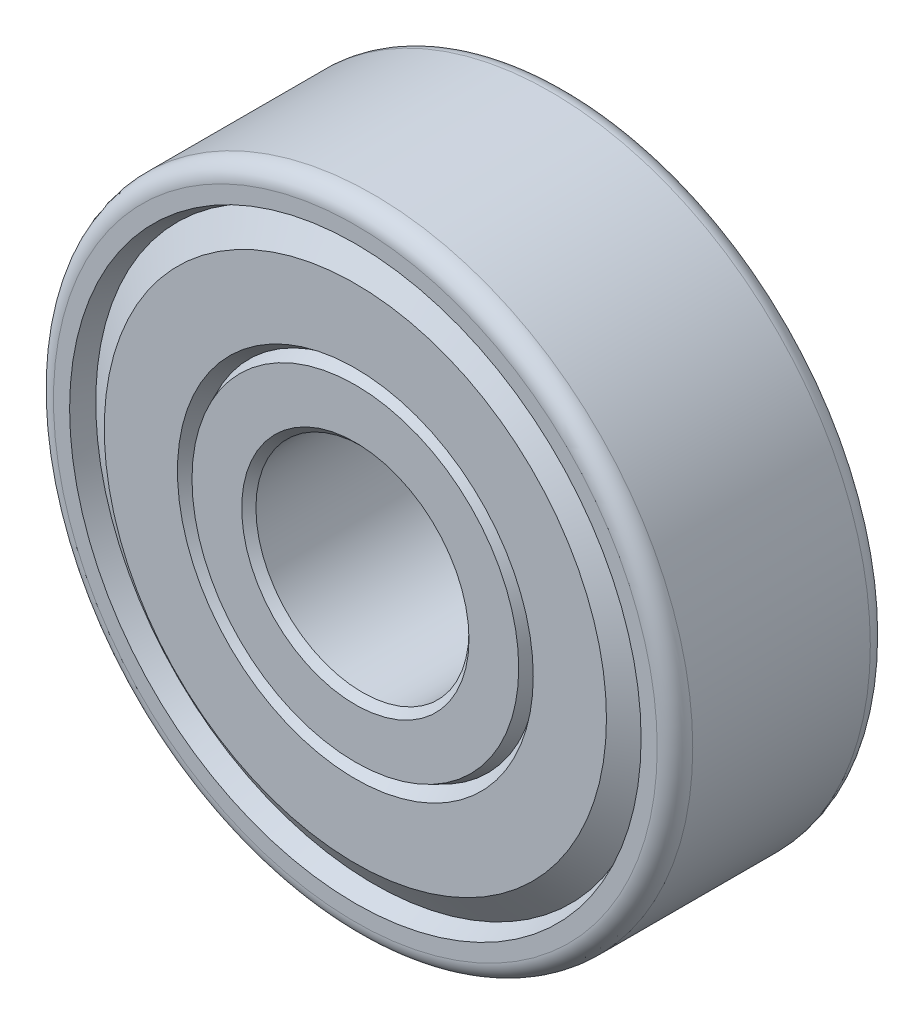
from build123d import *


with BuildPart() as part:
    # Esquisse1 → Révolution1 (revolve)
    with BuildSketch(Plane(origin=(0, 0, 0), x_dir=(1, 0, 0), z_dir=(0, 1, 0))):
        with BuildLine():
            Line((5.08, 4.7625), (4.7625, 4.445))
            Line((4.7625, 4.445), (4.7625, -4.445))
            Line((4.7625, -4.445), (5.08, -4.7625))
            Line((5.08, -4.7625), (7.3025, -4.7625))
            Line((7.3025, -4.7625), (7.553657425, -4.181328901))
            Line((7.553657425, -4.181328901), (7.952136973, -4.7625))
            Line((7.952136973, -4.7625), (11.224132695, -4.7625))
            Line((11.224132695, -4.7625), (12.438060247, -3.930171442))
            Line((12.438060247, -3.930171442), (12.772936813, -4.7625))
            Line((12.772936813, -4.7625), (13.49375, -4.7625))
            ThreePointArc((13.49375, -4.7625), (14.055016008, -4.530016008), (14.2875, -3.96875))
            Line((14.2875, -3.96875), (14.2875, 3.96875))
            ThreePointArc((14.2875, 3.96875), (14.055016008, 4.530016007), (13.49375, 4.7625))
            Line((13.49375, 4.7625), (12.772936813, 4.7625))
            Line((12.772936813, 4.7625), (12.438060247, 3.930171442))
            Line((12.438060247, 3.930171442), (11.224132694, 4.7625))
            Line((11.224132694, 4.7625), (7.952136973, 4.7625))
            Line((7.952136973, 4.7625), (7.553657425, 4.1813289))
            Line((7.553657425, 4.1813289), (7.3025, 4.7625))
            Line((7.3025, 4.7625), (5.08, 4.7625))
        make_face()
    revolve(axis=Axis((0, 0, -4.76375), (0, 0, 1)))


solid = part.part
